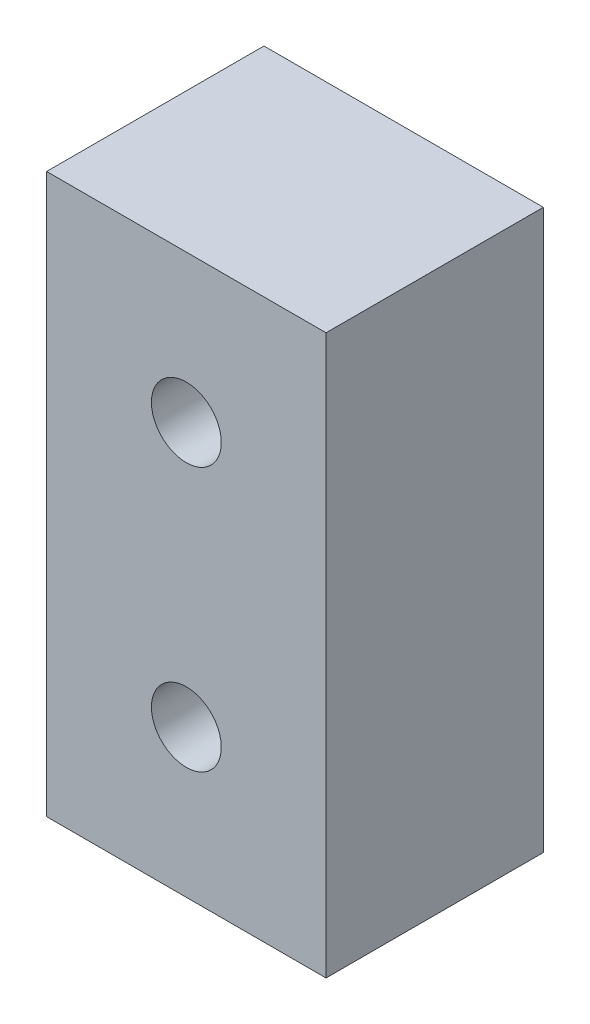
from build123d import *

# Parameters (mm, degrees)
ESQUISSE1_W                                        = 18
ESQUISSE1_H                                        = 36
BOSS_EXTRU_1_DEPTH                                 = 7
CHAMBRAGE_POUR_VIS_T_TE_HEXAGONALE_M41_D           = 4.5
CHAMBRAGE_POUR_VIS_T_TE_HEXAGONALE_M41_CBORE_D     = 8
CHAMBRAGE_POUR_VIS_T_TE_HEXAGONALE_M41_CBORE_DEPTH = 4.4


with BuildPart() as part:
    # Esquisse1 → Boss.-Extru.1 (new body, symmetric)
    with BuildSketch(Plane.XY):
        Rectangle(ESQUISSE1_W, ESQUISSE1_H)
    extrude(amount=BOSS_EXTRU_1_DEPTH, both=True)

    # Chambrage pour vis à tête hexagonale M41 (through all)
    with Locations(Plane(origin=(0, 0, -7), x_dir=(-1, 0, 0), z_dir=(0, 0, -1))):
        with Locations((0, 8.5), (0, -8.5)):
            CounterBoreHole(CHAMBRAGE_POUR_VIS_T_TE_HEXAGONALE_M41_D / 2, CHAMBRAGE_POUR_VIS_T_TE_HEXAGONALE_M41_CBORE_D / 2, CHAMBRAGE_POUR_VIS_T_TE_HEXAGONALE_M41_CBORE_DEPTH)


solid = part.part
